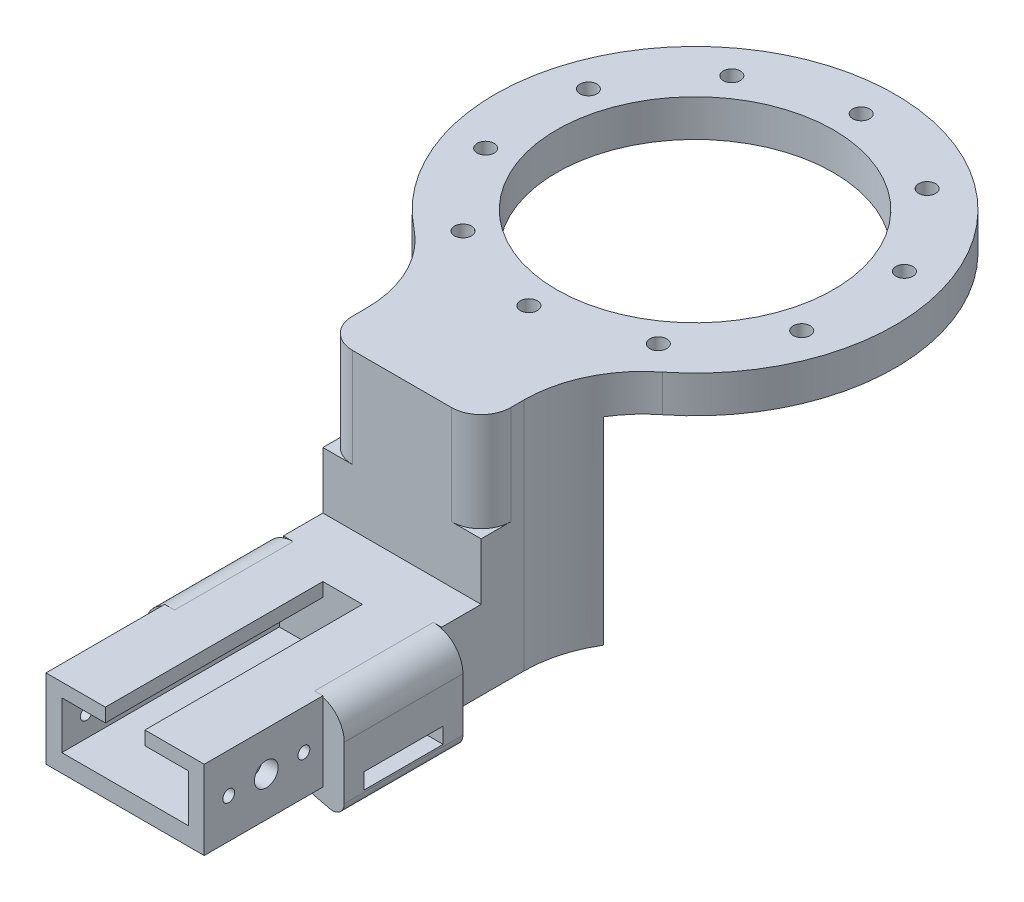
from build123d import *

# Parameters (mm, degrees)
SKETCH2_R           = 2.152402862
SKETCH2_R_2         = 35
BOSS_EXTRUDE2_DEPTH = 9.35
BOSS_EXTRUDE3_DEPTH = 50
CUT_EXTRUDE2_DEPTH  = 25
SKETCH8_W           = 40
SKETCH8_H           = 10
BOSS_EXTRUDE4_DEPTH = 20
BOSS_EXTRUDE5_DEPTH = 30
CUT_EXTRUDE4_DEPTH  = 56
SKETCH15_W          = 40
SKETCH15_H          = 20
BOSS_EXTRUDE6_DEPTH = 30
CUT_EXTRUDE5_DEPTH  = 55
SKETCH18_R          = 3
SKETCH18_R_2        = 1.5
CUT_EXTRUDE6_DEPTH  = 42


with BuildPart() as part:
    # Sketch2 → Boss-Extrude2 (new body)
    with BuildSketch(Plane(origin=(0, 0, 0), x_dir=(1, 0, 0), z_dir=(0, 1, 0))):
        with BuildLine():
            Line((-20, -74.081467259), (-20, -63.193139387))
            ThreePointArc((-20, -63.193139387), (-22.995916419, -50.124877454), (-31.385297997, -39.66671022))
            ThreePointArc((-31.385297997, -39.66671022), (0, 50.581467259), (31.385297997, -39.66671022))
            ThreePointArc((31.385297997, -39.66671022), (22.995916419, -50.124877454), (20, -63.193139387))
            Line((20, -63.193139387), (20, -74.081467259))
            Line((20, -74.081467259), (-20, -74.081467259))
        make_face()
        with Locations((0, 42)):
            Circle(SKETCH2_R, mode=Mode.SUBTRACT)
        with Locations((24.686980596, 33.978713764)):
            Circle(SKETCH2_R, mode=Mode.SUBTRACT)
        with Locations((39.944373684, 12.978713764)):
            Circle(SKETCH2_R, mode=Mode.SUBTRACT)
        with Locations((39.944373684, -12.978713764)):
            Circle(SKETCH2_R, mode=Mode.SUBTRACT)
        with Locations((24.686980596, -33.978713764)):
            Circle(SKETCH2_R, mode=Mode.SUBTRACT)
        with Locations((0, -42)):
            Circle(SKETCH2_R, mode=Mode.SUBTRACT)
        with Locations((-24.686980596, -33.978713764)):
            Circle(SKETCH2_R, mode=Mode.SUBTRACT)
        with Locations((-39.944373684, -12.978713764)):
            Circle(SKETCH2_R, mode=Mode.SUBTRACT)
        with Locations((-39.944373684, 12.978713764)):
            Circle(SKETCH2_R, mode=Mode.SUBTRACT)
        with Locations((-24.686980596, 33.978713764)):
            Circle(SKETCH2_R, mode=Mode.SUBTRACT)
        Circle(SKETCH2_R_2, mode=Mode.SUBTRACT)
    extrude(amount=BOSS_EXTRUDE2_DEPTH)

    # Sketch4 → Boss-Extrude3 (add)
    with BuildSketch(Plane.XZ):
        with BuildLine():
            Line((20, 74.081467259), (-20, 74.081467259))
            Line((-20, 74.081467259), (-20, 63.193139387))
            ThreePointArc((-20, 63.193139387), (-20.356412905, 58.582527267), (-21.417182941, 54.081467259))
            ThreePointArc((-21.417182941, 54.081467259), (-22.429520384, 51.366531516), (-23.699050675, 48.761920984))
            ThreePointArc((-23.699050675, 48.761920984), (0.438017323, 51.077240228), (24.422779297, 47.514944939))
            ThreePointArc((24.422779297, 47.514944939), (22.721671121, 50.70743662), (21.417182941, 54.081467259))
            ThreePointArc((21.417182941, 54.081467259), (20.356412905, 58.582527267), (20, 63.193139387))
            Line((20, 63.193139387), (20, 74.081467259))
        make_face()
    extrude(amount=BOSS_EXTRUDE3_DEPTH)

    # Sketch6 → Cut-Extrude2 (cut)
    with BuildSketch(Plane(origin=(0, 9.35, 0), x_dir=(1, 0, 0), z_dir=(0, 1, 0))):
        with BuildLine():
            Line((-12.5, -74.081467259), (-20, -74.081467259))
            Line((-20, -74.081467259), (-20, -66.581467259))
            ThreePointArc((-20, -66.581467259), (-17.803300859, -71.884768118), (-12.5, -74.081467259))
        make_face()
        with BuildLine():
            Line((12.5, -74.081467259), (20, -74.081467259))
            Line((20, -74.081467259), (20, -66.581467259))
            ThreePointArc((20, -66.581467259), (17.803300859, -71.884768118), (12.5, -74.081467259))
        make_face()
    extrude(amount=-CUT_EXTRUDE2_DEPTH, mode=Mode.SUBTRACT)

    # Sketch8 → Boss-Extrude4 (add)
    with BuildSketch(Plane(origin=(0, -50, 0), x_dir=(-1, 0, 0), z_dir=(0, -1, 0))):
        with Locations((0, -79.081467259)):
            Rectangle(SKETCH8_W, SKETCH8_H)
    extrude(amount=-BOSS_EXTRUDE4_DEPTH)

    # Sketch10 → Boss-Extrude5 (add)
    with BuildSketch(Plane.XY.offset(84.081467259)):
        with BuildLine():
            Line((-25, -37.5), (-25, -50.951484801))
            ThreePointArc((-25, -50.951484801), (-23.815635647, -53.339678092), (-21.197688536, -53.842210716))
            ThreePointArc((-21.197688536, -53.842210716), (0.197283847, -50.928235109), (21.59225623, -53.842210716))
            ThreePointArc((21.59225623, -53.842210716), (24.210203342, -53.339678092), (25.394567694, -50.951484801))
            Line((25.394567694, -50.951484801), (25.394567694, -37.5))
            ThreePointArc((25.394567694, -37.5), (23.197868553, -32.196699141), (17.894567694, -30))
            Line((17.894567694, -30), (-17.5, -30))
            ThreePointArc((-17.5, -30), (-22.803300859, -32.196699141), (-25, -37.5))
        make_face()
    extrude(amount=BOSS_EXTRUDE5_DEPTH)

    # Sketch11 → Cut-Extrude4 (cut)
    with BuildSketch(Plane.ZY.offset(25)):
        Polygon((109.081467259, -46.451484801), (109.081467259, -50.451484801), (99.081467259, -50.451484801), (89.081467259, -50.451484801), (89.081467259, -46.451484801), align=None)
    extrude(amount=-CUT_EXTRUDE4_DEPTH, mode=Mode.SUBTRACT)

    # Sketch15 → Boss-Extrude6 (add)
    with BuildSketch(Plane.XY.offset(114.081467259)):
        with Locations((0, -40)):
            Rectangle(SKETCH15_W, SKETCH15_H)
    extrude(amount=BOSS_EXTRUDE6_DEPTH)

    # Sketch17 → Cut-Extrude5 (cut)
    with BuildSketch(Plane.XY.offset(144.081467259)):
        Polygon((5, -30), (5, -33.451484801), (16, -33.451484801), (16, -45.451484801), (-16, -45.451484801), (-16, -33.451484801), (-5, -33.451484801), (-5, -30), align=None)
    extrude(amount=-CUT_EXTRUDE5_DEPTH, mode=Mode.SUBTRACT)

    # Sketch18 → Cut-Extrude6 (cut)
    with BuildSketch(Plane(origin=(20, 0, 0), x_dir=(0, 0, -1), z_dir=(1, 0, 0))):
        with Locations((-128.392898154, -40)):
            Circle(SKETCH18_R)
        with Locations((-118.892898154, -40)):
            Circle(SKETCH18_R_2)
        with Locations((-137.892898154, -40)):
            Circle(SKETCH18_R_2)
    extrude(amount=-CUT_EXTRUDE6_DEPTH, mode=Mode.SUBTRACT)


solid = part.part
